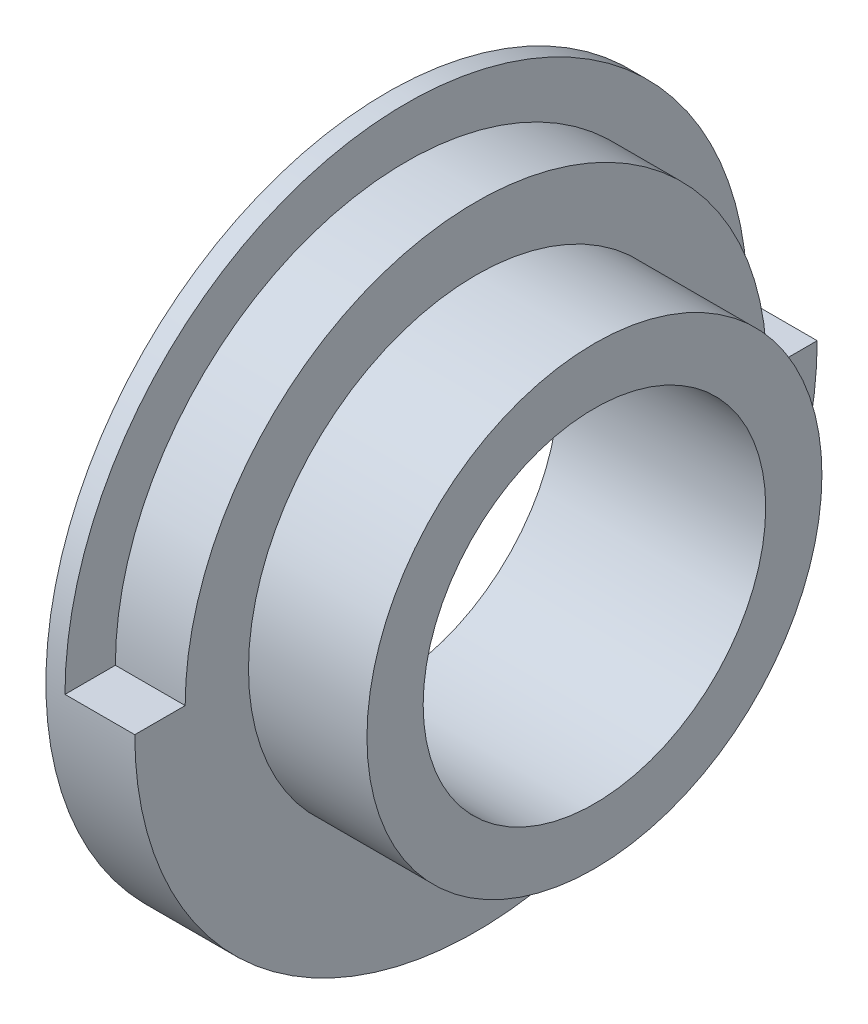
from build123d import *

# Parameters (mm, degrees)
IZIM2_W           = 24.151632934
IZIM2_H           = 17.006179403
KES_D_ND_R1_ANGLE = 180


with BuildPart() as part:
    # Çizim1 → Döndür1 (revolve)
    with BuildSketch(Plane.XY):
        Polygon((0, 29.195939483), (-35.343100252, 29.195939483), (-35.343100252, 58.1627654), (-20.19122208, 58.1627654), (-20.19122208, 38.777274209), (0, 38.777274209), align=None)
    revolve(axis=Axis((0, 0, 0), (-1, 0, 0)))

    # Çizim2 → Kes-Döndür1 (revolve, symmetric, cut)
    with BuildSketch(Plane.XY) as kes_d_nd_r1_sk:
        with Locations((-20.013486139, 58.073305733)):
            Rectangle(IZIM2_W, IZIM2_H)
    revolve(axis=Axis((0, 0, 0), (-1, 0, 0)), revolution_arc=KES_D_ND_R1_ANGLE / 2, mode=Mode.SUBTRACT)
    revolve(kes_d_nd_r1_sk.sketch, axis=Axis((0, 0, 0), (1, 0, 0)), revolution_arc=KES_D_ND_R1_ANGLE / 2, mode=Mode.SUBTRACT)


solid = part.part
